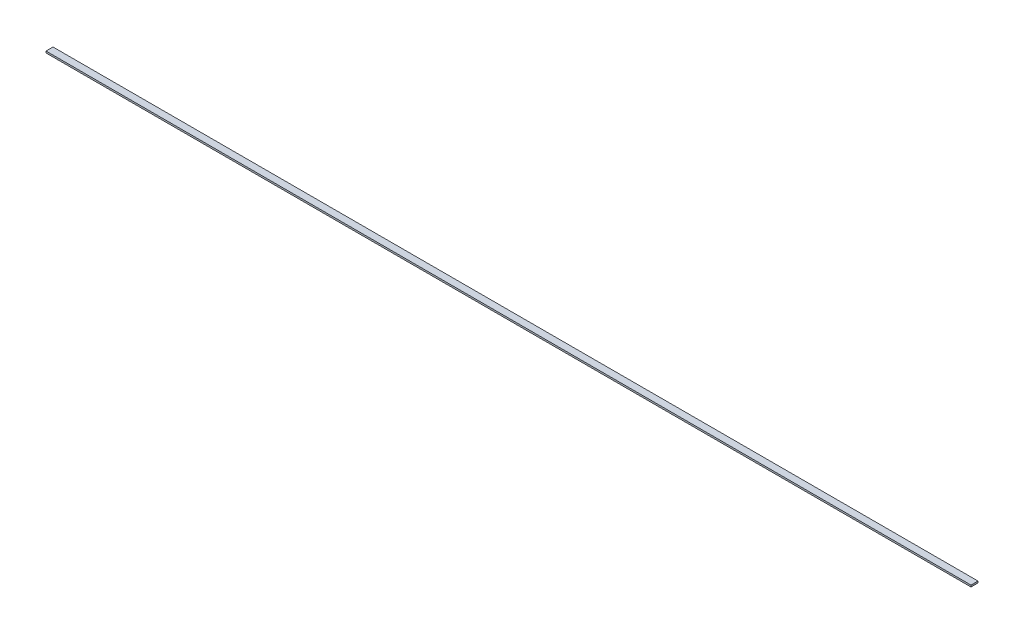
from build123d import *

# Parameters (mm, degrees)
SKETCH_1_W      = 592
SKETCH_1_H      = 4.479192938
EXTRUDE_1_DEPTH = 1.09


with BuildPart() as part:
    # Эскиз1 → Бобышка-Вытянуть1 (new body)
    with BuildSketch(Plane.XZ.offset(0.545)):
        with Locations((-2.612862547, 2.239596469)):
            Rectangle(SKETCH_1_W, SKETCH_1_H)
    extrude(amount=-EXTRUDE_1_DEPTH)


solid = part.part
